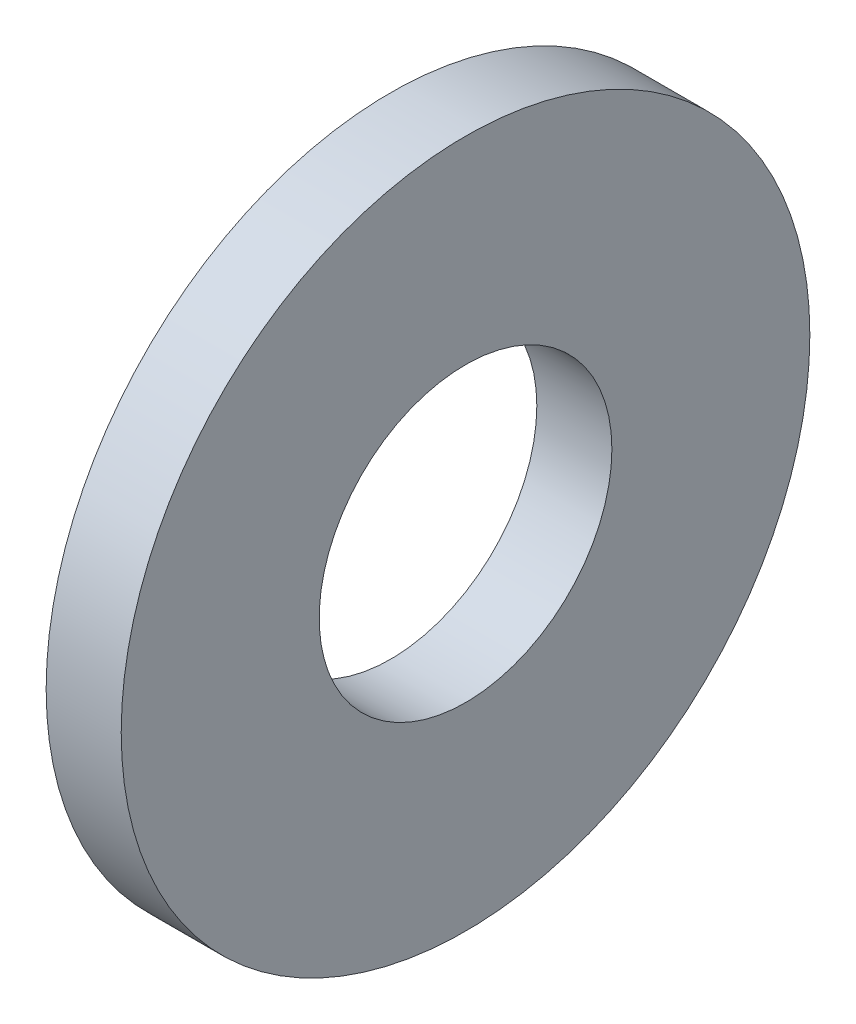
from build123d import *

# Parameters (mm, degrees)
SKETCH1_R           = 9.3218
SKETCH1_R_2         = 3.9624
BOSS_EXTRUDE1_DEPTH = 2.032


with BuildPart() as part:
    # Sketch1 → Boss-Extrude1 (new body)
    with BuildSketch(Plane(origin=(0, 0, 0), x_dir=(0, 0, -1), z_dir=(1, 0, 0))):
        Circle(SKETCH1_R)
        Circle(SKETCH1_R_2, mode=Mode.SUBTRACT)
    extrude(amount=BOSS_EXTRUDE1_DEPTH)


solid = part.part
